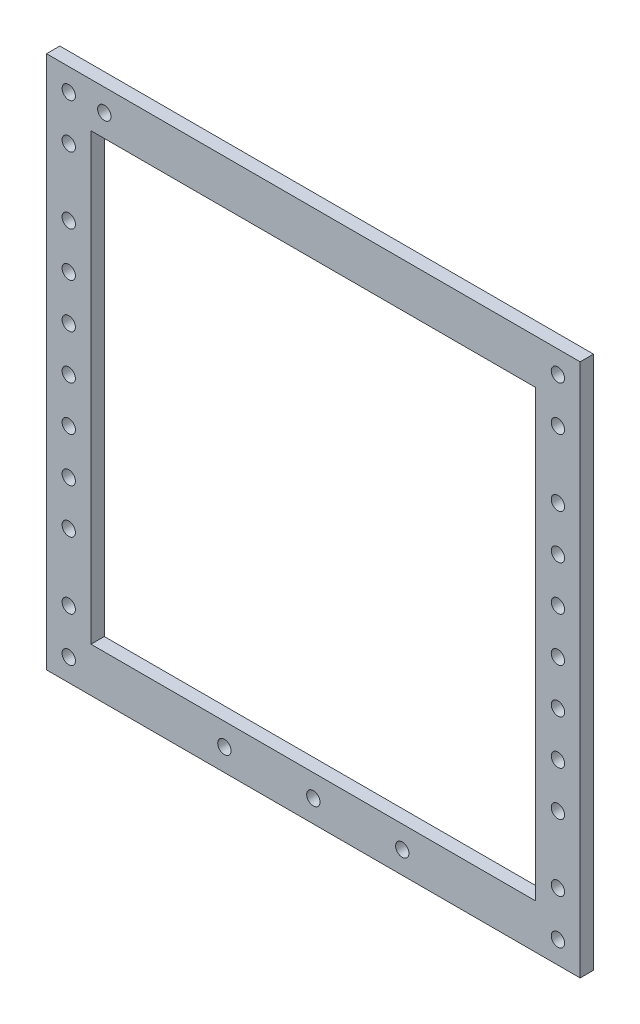
from build123d import *

# Parameters (mm, degrees)
ESBO_O1_W                = 120
ESBO_O1_H                = 120
RESSALTO_EXTRUS_O1_DEPTH = 3
ESBO_O2_W                = 100
ESBO_O2_H                = 100
CORTE_EXTRUS_O1_DEPTH    = 4
ESBO_O3_R                = 1.5
CORTE_EXTRUS_O2_DEPTH    = 4
ESBO_O4_R                = 1.5
CORTE_EXTRUS_O3_DEPTH    = 4
ESBO_O5_R                = 1.5
CORTE_EXTRUS_O4_DEPTH    = 4
ESBO_O6_R                = 1.5
CORTE_EXTRUS_O5_DEPTH    = 4


with BuildPart() as part:
    # Esboço1 → Ressalto-extrusão1 (new body)
    with BuildSketch(Plane.XY):
        with Locations((53.473096186, -53.653846154)):
            Rectangle(ESBO_O1_W, ESBO_O1_H)
    extrude(amount=RESSALTO_EXTRUS_O1_DEPTH)

    # Esboço2 → Corte-extrusão1 (cut, through all)
    with BuildSketch(Plane.XY.offset(3)):
        with Locations((53.473096186, -53.653846154)):
            Rectangle(ESBO_O2_W, ESBO_O2_H)
    extrude(amount=-CORTE_EXTRUS_O1_DEPTH, mode=Mode.SUBTRACT)

    # Esboço3 → Corte-extrusão2 (cut, through all)
    with BuildSketch(Plane.XY.offset(3)):
        with Locations((-1.526903814, 1.346153846)):
            Circle(ESBO_O3_R)
        with Locations((-1.526903814, -108.653846154)):
            Circle(ESBO_O3_R)
        with Locations((-1.526903814, -33.653846154)):
            Circle(ESBO_O3_R)
        with Locations((-1.526903814, -53.653846154)):
            Circle(ESBO_O3_R)
        with Locations((-1.526903814, -73.653846154)):
            Circle(ESBO_O3_R)
        with Locations((108.473096186, -73.653846154)):
            Circle(ESBO_O3_R)
        with Locations((108.473096186, -53.653846154)):
            Circle(ESBO_O3_R)
        with Locations((108.473096186, -33.653846154)):
            Circle(ESBO_O3_R)
        with Locations((108.473096186, -108.653846154)):
            Circle(ESBO_O3_R)
        with Locations((108.473096186, 1.346153846)):
            Circle(ESBO_O3_R)
    extrude(amount=-CORTE_EXTRUS_O2_DEPTH, mode=Mode.SUBTRACT)

    # Esboço4 → Corte-extrusão3 (cut, through all)
    with BuildSketch(Plane.XY.offset(3)):
        with Locations((6.473096186, 1.346153846)):
            Circle(ESBO_O4_R)
    extrude(amount=-CORTE_EXTRUS_O3_DEPTH, mode=Mode.SUBTRACT)

    # Esboço5 → Corte-extrusão4 (cut, through all)
    with BuildSketch(Plane.XY.offset(3)):
        with Locations((73.473096186, -108.653846154)):
            Circle(ESBO_O5_R)
        with Locations((53.473096186, -108.653846154)):
            Circle(ESBO_O5_R)
        with Locations((33.473096186, -108.653846154)):
            Circle(ESBO_O5_R)
    extrude(amount=-CORTE_EXTRUS_O4_DEPTH, mode=Mode.SUBTRACT)

    # Esboço6 → Corte-extrusão5 (cut, through all)
    with BuildSketch(Plane.XY.offset(3)):
        with Locations((108.473096186, -23.653846154)):
            Circle(ESBO_O6_R)
        with Locations((108.473096186, -43.653846154)):
            Circle(ESBO_O6_R)
        with Locations((108.473096186, -63.653846154)):
            Circle(ESBO_O6_R)
        with Locations((108.473096186, -83.653846154)):
            Circle(ESBO_O6_R)
        with Locations((-1.526903814, -83.653846154)):
            Circle(ESBO_O6_R)
        with Locations((-1.526903814, -63.653846154)):
            Circle(ESBO_O6_R)
        with Locations((-1.526903814, -43.653846154)):
            Circle(ESBO_O6_R)
        with Locations((-1.526903814, -23.653846154)):
            Circle(ESBO_O6_R)
        with Locations((108.473096186, -8.653846154)):
            Circle(ESBO_O6_R)
        with Locations((108.473096186, -98.653846154)):
            Circle(ESBO_O6_R)
        with Locations((-1.526903814, -98.653846154)):
            Circle(ESBO_O6_R)
        with Locations((-1.526903814, -8.653846154)):
            Circle(ESBO_O6_R)
    extrude(amount=-CORTE_EXTRUS_O5_DEPTH, mode=Mode.SUBTRACT)


solid = part.part
